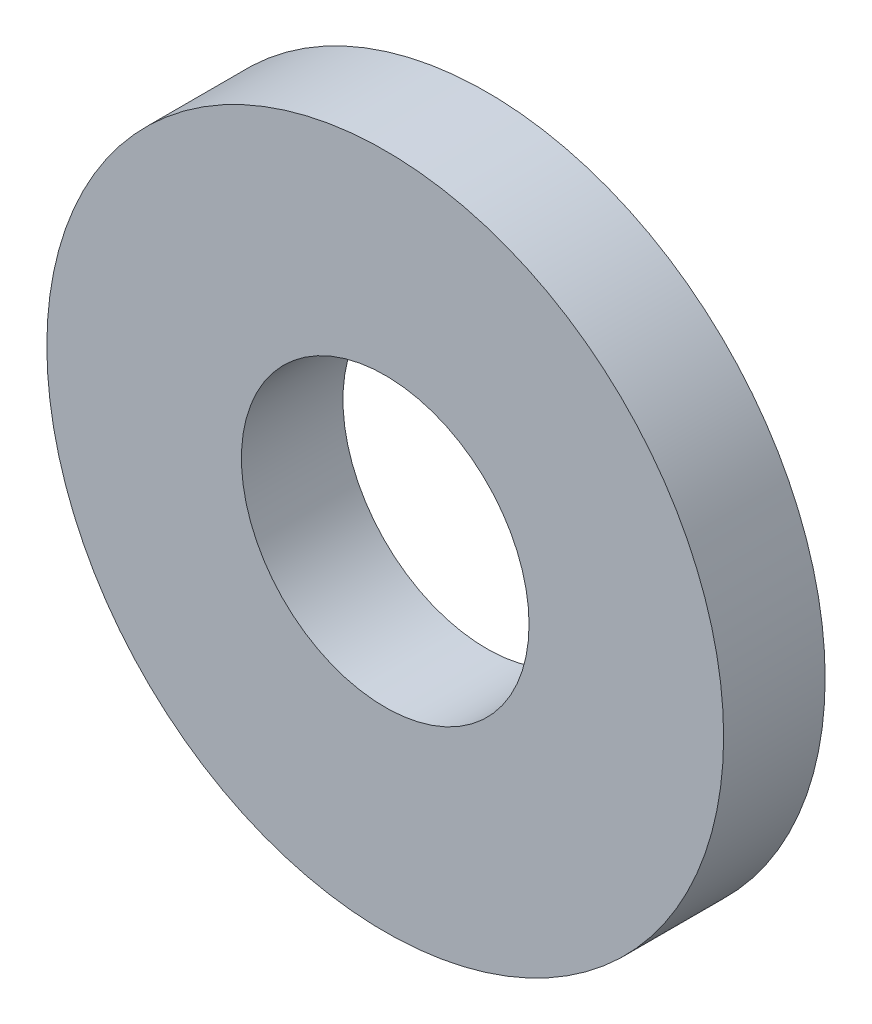
from build123d import *

# Parameters (mm, degrees)
SKETCH1_R           = 20
SKETCH1_R_2         = 8.5
BOSS_EXTRUDE1_DEPTH = 6


with BuildPart() as part:
    # Sketch1 → Boss-Extrude1 (new body)
    with BuildSketch(Plane.XY):
        with Locations((350, 60)):
            Circle(SKETCH1_R)
        with Locations((350, 60)):
            Circle(SKETCH1_R_2, mode=Mode.SUBTRACT)
    extrude(amount=BOSS_EXTRUDE1_DEPTH)


solid = part.part
